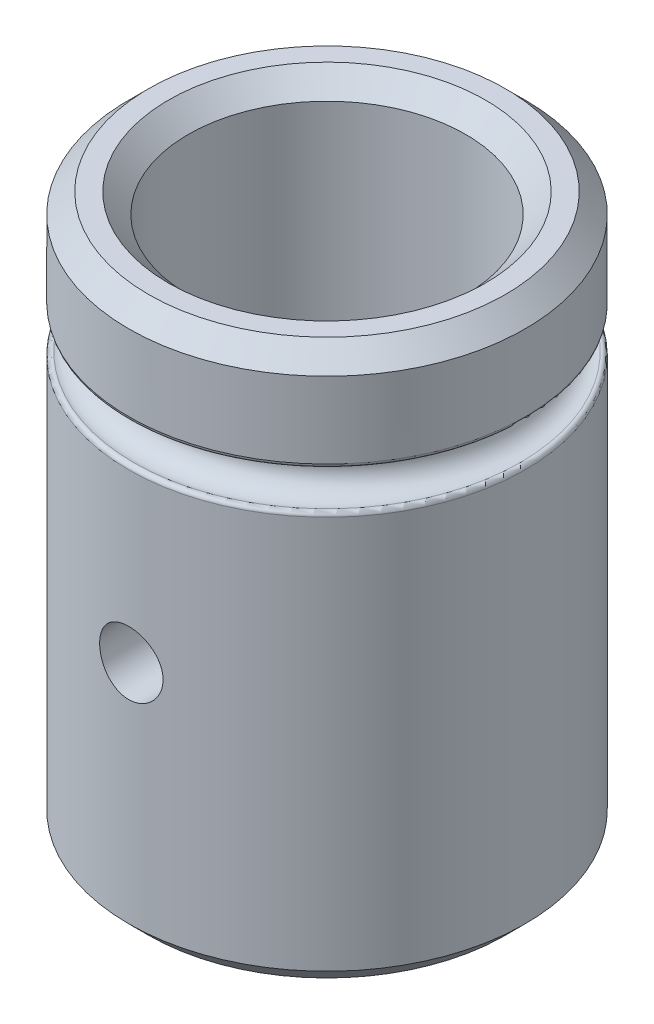
from build123d import *

# Parameters (mm, degrees)
SKETCH1_R           = 5
SKETCH1_R_2         = 3.5
BOSS_EXTRUDE1_DEPTH = 14
SKETCH3_R           = 0.8
CUT_EXTRUDE1_DEPTH  = 6
SKETCH4_R           = 0.5
FILLET1_R           = 0.1
CHAMFER1_SIZE       = 0.5


with BuildPart() as part:
    # Sketch1 → Boss-Extrude1 (new body)
    with BuildSketch(Plane(origin=(0, 0, 0), x_dir=(1, 0, 0), z_dir=(0, 1, 0))):
        Circle(SKETCH1_R)
        Circle(SKETCH1_R_2, mode=Mode.SUBTRACT)
    extrude(amount=BOSS_EXTRUDE1_DEPTH)

    # Sketch3 → Cut-Extrude1 (cut, through all)
    with BuildSketch(Plane.XY):
        with Locations((0, 6.2)):
            Circle(SKETCH3_R)
    extrude(amount=CUT_EXTRUDE1_DEPTH, mode=Mode.SUBTRACT)

    # Sketch4 → Cut-Revolve1 (revolve, cut)
    with BuildSketch(Plane.XY):
        with Locations((4.75, 11)):
            Circle(SKETCH4_R)
    revolve(axis=Axis((0, 0, 0), (0, 1, 0)), mode=Mode.SUBTRACT)

    # Fillet1
    fillet1_edges = [part.edges().sort_by_distance(p)[0] for p in [
        (-5, 11.433012702, 0),
        (-5, 10.566987298, 0),
    ]]
    fillet(fillet1_edges, radius=FILLET1_R)

    # Chamfer1
    chamfer1_edges = [part.edges().sort_by_distance(p)[0] for p in [
        (-5, 0, 0),
        (-5, 14, 0),
        (-3.5, 0, 0),
        (-3.5, 14, 0),
    ]]
    chamfer(chamfer1_edges, length=CHAMFER1_SIZE)


solid = part.part
